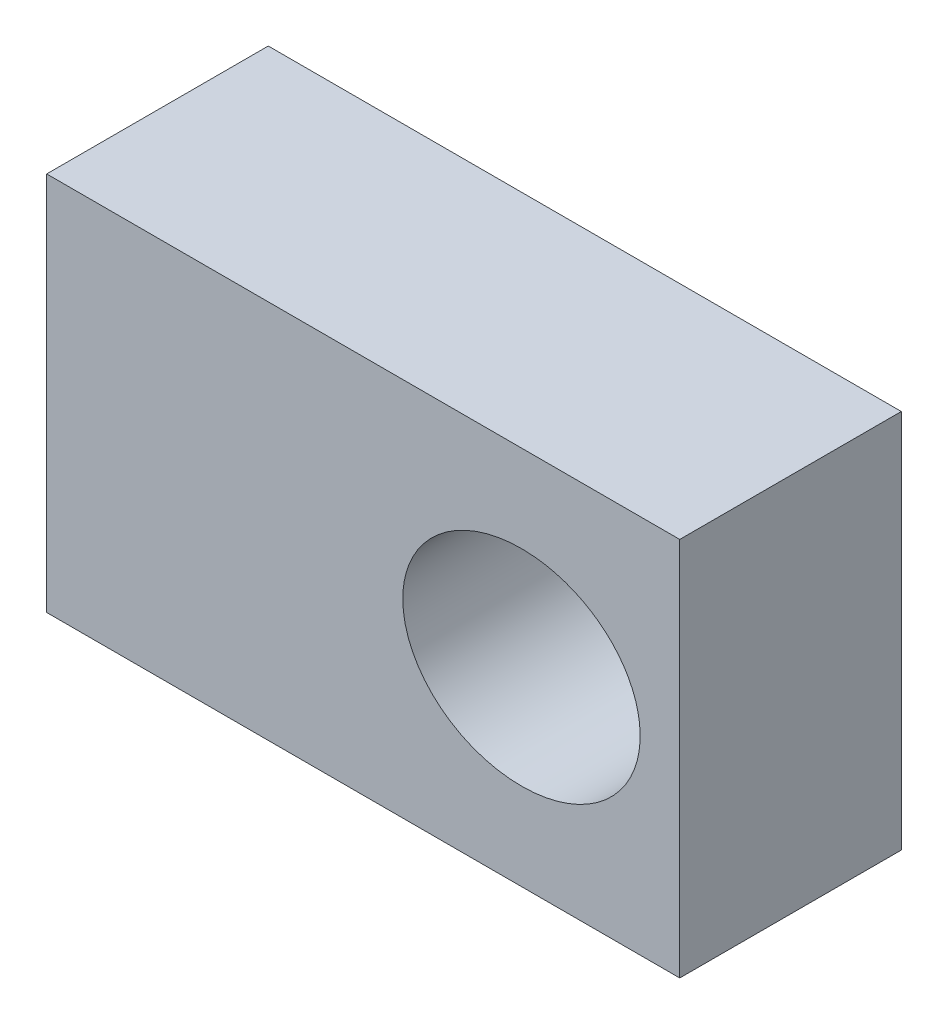
from build123d import *

# Parameters (mm, degrees)
SKETCH1_W           = 200
SKETCH1_H           = 120
SKETCH1_RX          = 37.5
SKETCH1_RY          = 32.5
BOSS_EXTRUDE1_DEPTH = 70


with BuildPart() as part:
    # Sketch1 → Boss-Extrude1 (new body)
    with BuildSketch(Plane.XY):
        with Locations((-50, 0)):
            Rectangle(SKETCH1_W, SKETCH1_H)
        with Locations(Location((0, 0), (0, 0, 180))):
            Ellipse(SKETCH1_RX, SKETCH1_RY, mode=Mode.SUBTRACT)
    extrude(amount=BOSS_EXTRUDE1_DEPTH)


solid = part.part
